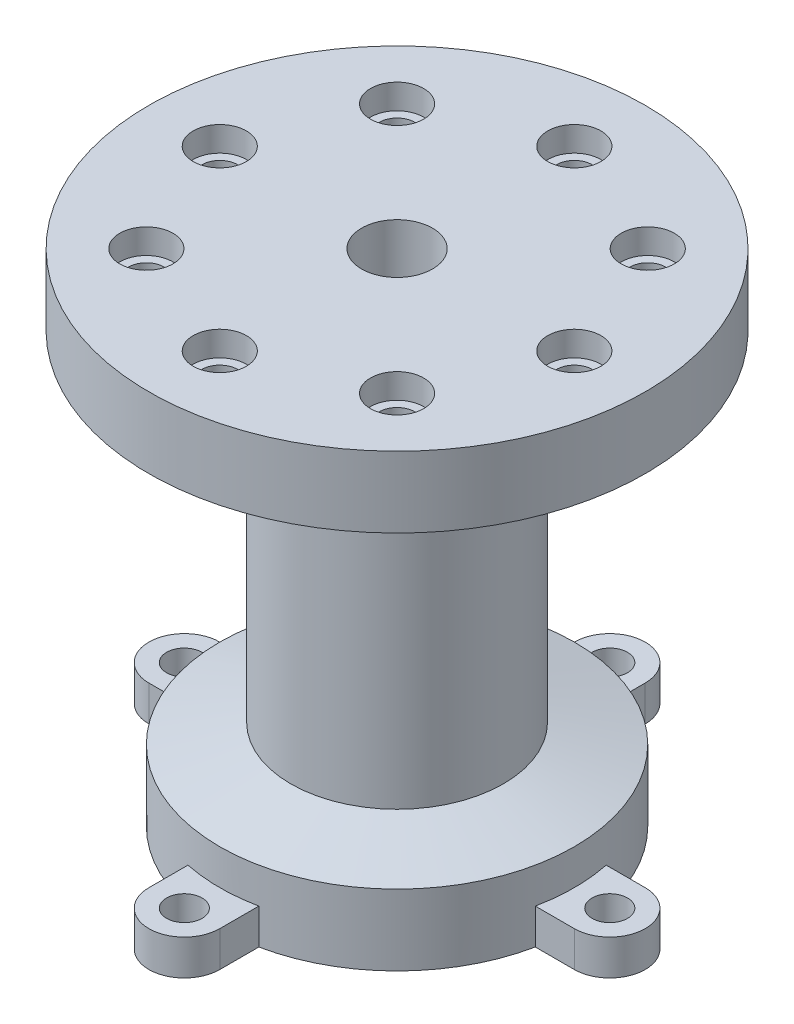
from build123d import *

# Parameters (mm, degrees)
SKETCH2_R           = 2.5
BOSS_EXTRUDE1_DEPTH = 5
CIRPATTERN1_COUNT   = 4
HOLE2_D             = 10
HOLE2_DEPTH         = 21.5
HOLE2_TIP           = 3.004303095
HOLE9_D             = 5
HOLE9_DEPTH         = 49.984372558
HOLE9_CBORE_D       = 7.5
HOLE9_CBORE_DEPTH   = 3.5


with BuildPart() as part:
    # Sketch1 → Revolve1 (revolve)
    with BuildSketch(Plane.XY):
        Polygon((0, 0), (25, 0), (25, 10), (15, 12.679491924), (15, 55.197679104), (35, 60.556662953), (35, 70.556662953), (0, 70.556662953), align=None)
    revolve(axis=Axis((0, 0, 0), (0, 1, 0)))

    # Sketch2 → Boss-Extrude1 (add)
    with BuildSketch(Plane(origin=(0, 0, 0), x_dir=(1, 0, 0), z_dir=(0, 1, 0))):
        with BuildLine():
            Line((-5, -30), (-5, -24.494897428))
            ThreePointArc((-5, -24.494897428), (0, -25), (5, -24.494897428))
            Line((5, -24.494897428), (5, -30))
            ThreePointArc((5, -30), (0, -35), (-5, -30))
        make_face()
        with Locations((0, -30)):
            Circle(SKETCH2_R, mode=Mode.SUBTRACT)
    boss_extrude1 = extrude(amount=BOSS_EXTRUDE1_DEPTH)

    # CirPattern1: Boss-Extrude1 ×4 about axis
    cirpattern1_axis = Axis((0, 0, 0), (0, 1, 0))
    for i in range(1, CIRPATTERN1_COUNT):
        add(boss_extrude1.rotate(cirpattern1_axis, i * 360 / CIRPATTERN1_COUNT))

    # Hole2
    with Locations(Plane(origin=(0, 70.556662953, 0), x_dir=(1, 0, 0), z_dir=(0, 1, 0))):
        with Locations((0, 0)):
            Hole(HOLE2_D / 2, depth=HOLE2_DEPTH)
            with Locations((0, 0, -(HOLE2_DEPTH + HOLE2_TIP / 2))):  # 118° drill point
                Cone(0, HOLE2_D / 2, HOLE2_TIP, mode=Mode.SUBTRACT)

    # Hole9
    with Locations(Plane(origin=(0, 70.556662953, 0), x_dir=(1, 0, 0), z_dir=(0, 1, 0))):
        with Locations((-17.67766953, 17.67766953), (0, 25), (17.67766953, 17.67766953), (25, 0), (17.67766953, -17.67766953), (0, -25), (-17.67766953, -17.67766953), (-25, 0)):
            CounterBoreHole(HOLE9_D / 2, HOLE9_CBORE_D / 2, HOLE9_CBORE_DEPTH, depth=HOLE9_DEPTH)


solid = part.part
